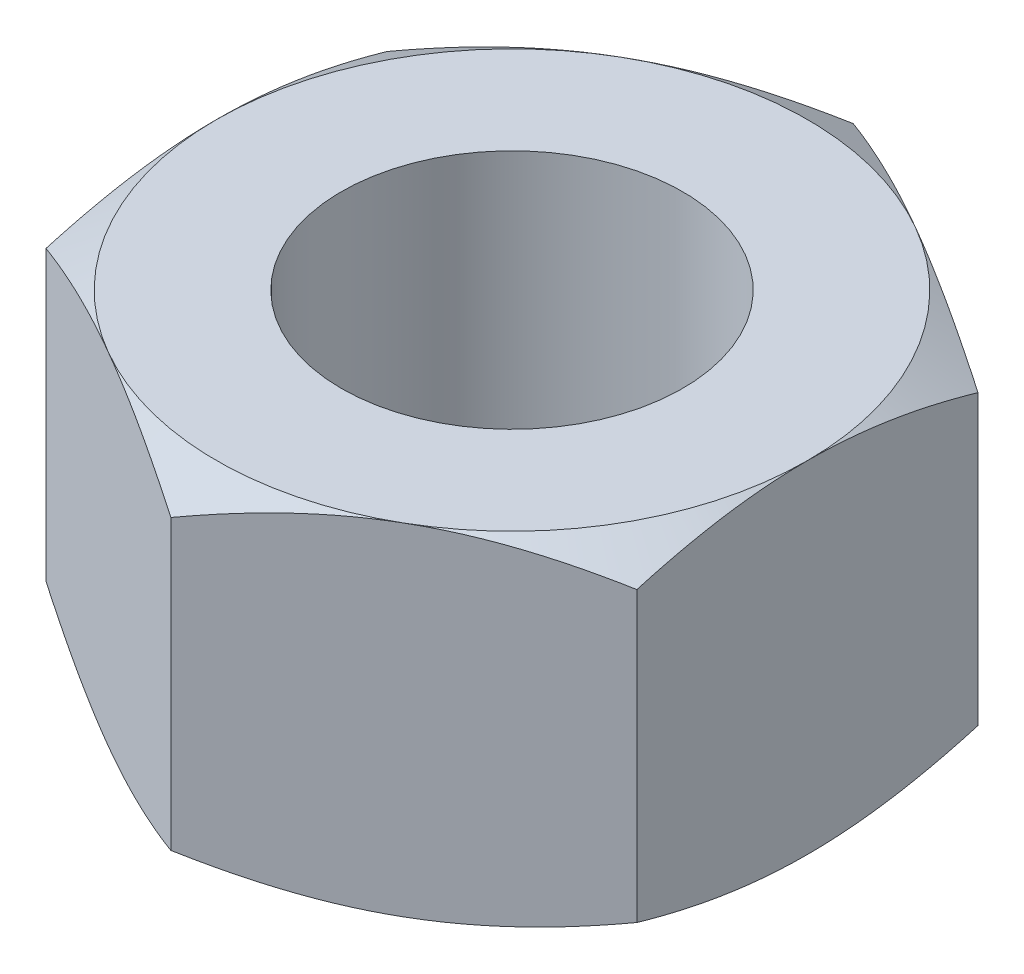
from build123d import *

# Parameters (mm, degrees)
SKETCH1_R           = 4.5
BOSS_EXTRUDE1_DEPTH = 4.5
SKETCH2_OUTSIDE_W   = 57.32
SKETCH2_OUTSIDE_H   = 59.732
SKETCH2_OUTSIDE_R   = 7.794228634
CUT_EXTRUDE1_DEPTH  = 10
CUT_EXTRUDE1_TAPER  = 60


with BuildPart() as part:
    # Sketch1 → Boss-Extrude1 (new body, symmetric)
    with BuildSketch(Plane(origin=(0, 0, 0), x_dir=(1, 0, 0), z_dir=(0, 1, 0))):
        Polygon((0, -9), (7.794228634, -4.5), (7.794228634, 4.5), (0, 9), (-7.794228634, 4.5), (-7.794228634, -4.5), align=None)
        with Locations(Location((0, 0, 0), (0, 0, 270))):  # turned: the seam where the file's is
            Circle(SKETCH1_R, mode=Mode.SUBTRACT)
    extrude(amount=BOSS_EXTRUDE1_DEPTH, both=True)

    # Sketch2 outside → Cut-Extrude1 (cut)
    with BuildSketch(Plane(origin=(0, 4.5, 0), x_dir=(1, 0, 0), z_dir=(0, 1, 0))):
        Rectangle(SKETCH2_OUTSIDE_W, SKETCH2_OUTSIDE_H)
        Circle(SKETCH2_OUTSIDE_R, mode=Mode.SUBTRACT)
    cut_extrude1 = extrude(amount=-CUT_EXTRUDE1_DEPTH, taper=CUT_EXTRUDE1_TAPER, mode=Mode.SUBTRACT)

    # Mirror1: Cut-Extrude1 across plane
    add(cut_extrude1.mirror(Plane.ZX), mode=Mode.SUBTRACT)


solid = part.part
